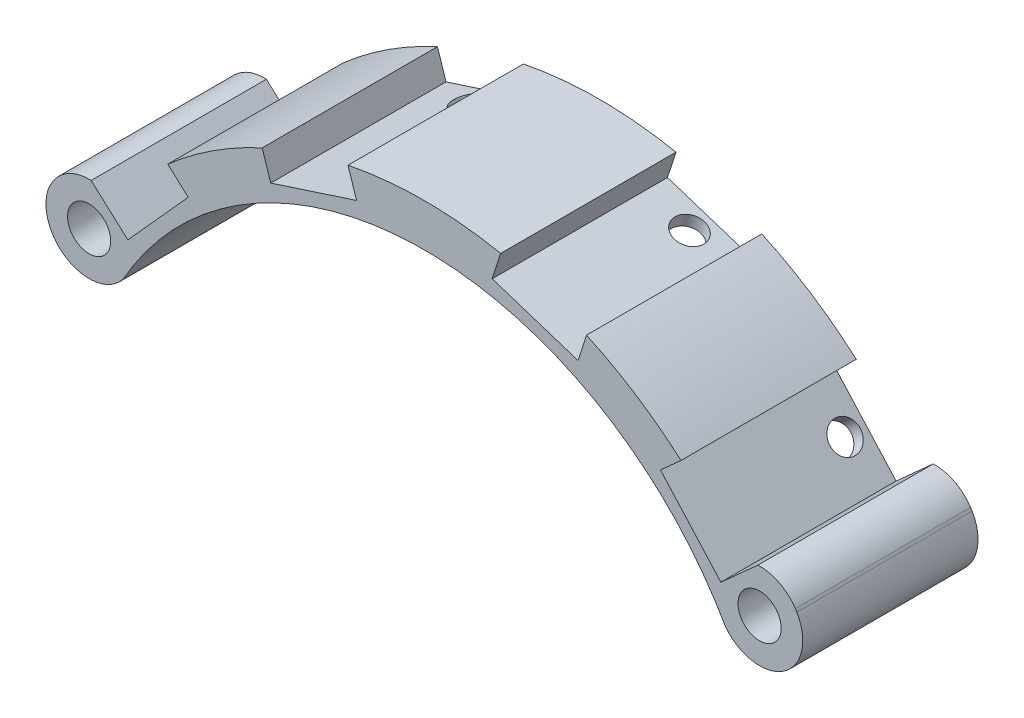
from build123d import *

# Parameters (mm, degrees)
ESBO_O2_R                = 2.5
RESSALTO_EXTRUS_O1_DEPTH = 20.3
ESBO_O3_R                = 1.75
CORTE_EXTRUS_O1_DEPTH    = 20.3
ESBO_O4_W                = 10.45
ESBO_O4_H                = 20.3
CORTE_EXTRUS_O3_DEPTH    = 8.5
ESBO_O5_W                = 20.3
ESBO_O5_H                = 10.45
CORTE_EXTRUS_O4_DEPTH    = 8.5
ESBO_O6_W                = 10.45
ESBO_O6_H                = 20.3
CORTE_EXTRUS_O5_DEPTH    = 8.5
ESBO_O7_W                = 20.3
ESBO_O7_H                = 10.45
CORTE_EXTRUS_O6_DEPTH    = 8.5
ESBO_O8_R                = 1.75
CORTE_EXTRUS_O7_DEPTH    = 8
ESBO_O10_R               = 1.75
CORTE_EXTRUS_O8_DEPTH    = 8
ESBO_O9_R                = 1.75
CORTE_EXTRUS_O9_DEPTH    = 8
CORTE_EXTRUS_O10_DEPTH   = 21.3000001
CORTE_EXTRUS_O13_DEPTH   = 21.3000001


with BuildPart() as part:
    # Esboço2 → Ressalto-extrusão1 (new body)
    with BuildSketch(Plane.XY):
        with BuildLine():
            ThreePointArc((43.137997257, 25.280688137), (0, 50), (-43.137997257, 25.280688137))
            ThreePointArc((-43.137997257, 25.280688137), (-41.634338387, 18.617028874), (-34.88523184, 19.672919779))
            ThreePointArc((-34.88523184, 19.672919779), (0, 40.050008404), (34.88523184, 19.672919779))
            ThreePointArc((34.88523184, 19.672919779), (41.634338387, 18.617028874), (43.137997257, 25.280688137))
        make_face()
        with Locations((-38.824197531, 22.752619324)):
            Circle(ESBO_O2_R, mode=Mode.SUBTRACT)
        with Locations((38.824197531, 22.752619324)):
            Circle(ESBO_O2_R, mode=Mode.SUBTRACT)
    extrude(amount=RESSALTO_EXTRUS_O1_DEPTH)

    # Esboço3 → Corte-extrusão1 (cut)
    with BuildSketch(Plane(origin=(15.450849719, 47.552825815, 0), x_dir=(0.951056516, -0.309016994, 0), z_dir=(0.309016994, 0.951056516, 0))):
        with Locations((0, -2.42)):
            Circle(ESBO_O3_R)
    extrude(amount=-CORTE_EXTRUS_O1_DEPTH, mode=Mode.SUBTRACT)

    # Esboço4 → Corte-extrusão3 (cut)
    with BuildSketch(Plane(origin=(15.450849719, 47.552825815, 0), x_dir=(0.951056516, -0.309016994, 0), z_dir=(0.309016994, 0.951056516, 0))):
        with Locations((0, -10.15)):
            Rectangle(ESBO_O4_W, ESBO_O4_H)
    extrude(amount=-CORTE_EXTRUS_O3_DEPTH, mode=Mode.SUBTRACT)

    # Esboço5 → Corte-extrusão4 (cut)
    with BuildSketch(Plane(origin=(37.157241274, 33.456530318, 0), x_dir=(0, 0, -1), z_dir=(0.743144825, 0.669130606, 0))):
        with Locations((-10.15, 0)):
            Rectangle(ESBO_O5_W, ESBO_O5_H)
    extrude(amount=-CORTE_EXTRUS_O4_DEPTH, mode=Mode.SUBTRACT)

    # Esboço6 → Corte-extrusão5 (cut)
    with BuildSketch(Plane(origin=(-15.450849719, 47.552825815, 0), x_dir=(0.951056516, 0.309016994, 0), z_dir=(-0.309016994, 0.951056516, 0))):
        with Locations((0, -10.15)):
            Rectangle(ESBO_O6_W, ESBO_O6_H)
    extrude(amount=-CORTE_EXTRUS_O5_DEPTH, mode=Mode.SUBTRACT)

    # Esboço7 → Corte-extrusão6 (cut)
    with BuildSketch(Plane(origin=(-37.157241274, 33.456530318, 0), x_dir=(0, 0, 1), z_dir=(-0.743144825, 0.669130606, 0))):
        with Locations((10.15, 0)):
            Rectangle(ESBO_O7_W, ESBO_O7_H)
    extrude(amount=-CORTE_EXTRUS_O6_DEPTH, mode=Mode.SUBTRACT)

    # Esboço8 → Corte-extrusão7 (cut)
    with BuildSketch(Plane(origin=(30.840510257, 27.768920164, 0), x_dir=(0, 0, -1), z_dir=(0.743144825, 0.669130606, 0))):
        with Locations((-2.42, 0)):
            Circle(ESBO_O8_R)
    extrude(amount=-CORTE_EXTRUS_O7_DEPTH, mode=Mode.SUBTRACT)

    # Esboço10 → Corte-extrusão8 (cut)
    with BuildSketch(Plane(origin=(-30.840510257, 27.768920164, 0), x_dir=(0, 0, 1), z_dir=(-0.743144825, 0.669130606, 0))):
        with Locations((2.42, 0)):
            Circle(ESBO_O10_R)
    extrude(amount=-CORTE_EXTRUS_O8_DEPTH, mode=Mode.SUBTRACT)

    # Esboço9 → Corte-extrusão9 (cut)
    with BuildSketch(Plane(origin=(-12.824205267, 39.468845426, 0), x_dir=(0.951056516, 0.309016994, 0), z_dir=(-0.309016994, 0.951056516, 0))):
        with Locations((0, -2.42)):
            Circle(ESBO_O9_R)
    extrude(amount=-CORTE_EXTRUS_O9_DEPTH, mode=Mode.SUBTRACT)

    # Esboço11 → Corte-extrusão10 (cut, through all)
    with BuildSketch(Plane.XY.offset(20.3)):
        with BuildLine():
            Line((-40.450008581, 29.390420306), (-38.593336029, 27.718664832))
            ThreePointArc((-38.593336029, 27.718664832), (-41.446519528, 26.976164323), (-43.377460924, 24.74828901))
            Line((-43.377460924, 24.74828901), (-42.327289397, 29.390420306))
            Line((-42.327289397, 29.390420306), (-40.450008581, 29.390420306))
        make_face()
        with BuildLine():
            Line((38.629484885, 27.751213408), (40.450008581, 29.390420306))
            Line((40.450008581, 29.390420306), (42.795606827, 28.974236974))
            Line((42.795606827, 28.974236974), (42.969901633, 25.552082367))
            ThreePointArc((42.969901633, 25.552082367), (41.08508844, 27.214931295), (38.629484885, 27.751213408))
        make_face()
    extrude(amount=-CORTE_EXTRUS_O10_DEPTH, mode=Mode.SUBTRACT)

    # Esboço13 → Corte-extrusão13 (cut, through all)
    with BuildSketch(Plane.XY.offset(20.3)):
        with BuildLine():
            Line((-43.591003867, 44.387154562), (-0.084802266, 65.050582409))
            Line((-0.084802266, 65.050582409), (44.470714032, 40.916344415))
            Line((44.470714032, 40.916344415), (33.115675704, 30.468869731))
            ThreePointArc((33.115675704, 30.468869731), (-0.45988999, 44.997649952), (-33.731495865, 29.785670828))
            Line((-33.731495865, 29.785670828), (-43.591003867, 44.387154562))
        make_face()
    extrude(amount=-CORTE_EXTRUS_O13_DEPTH, mode=Mode.SUBTRACT)


solid = part.part
